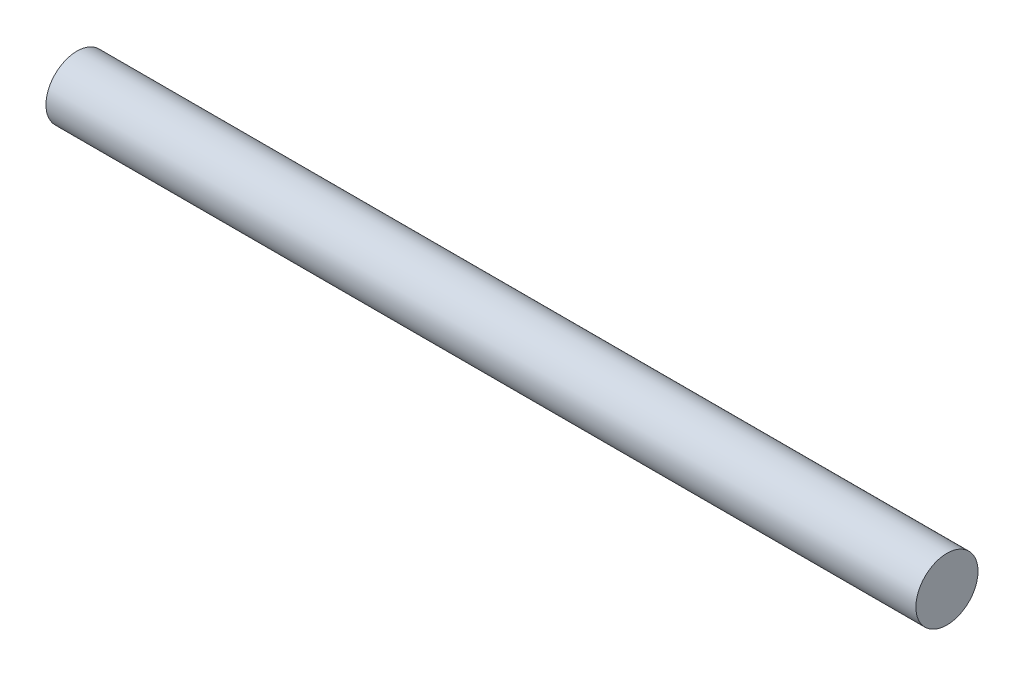
from build123d import *

# Parameters (mm, degrees)
SKETCH1_R           = 0.5
BOSS_EXTRUDE1_DEPTH = 14


with BuildPart() as part:
    # Sketch1 → Boss-Extrude1 (new body)
    with BuildSketch(Plane(origin=(0, 0, 0), x_dir=(0, 0, -1), z_dir=(1, 0, 0))):
        Circle(SKETCH1_R)
    extrude(amount=BOSS_EXTRUDE1_DEPTH)


solid = part.part
